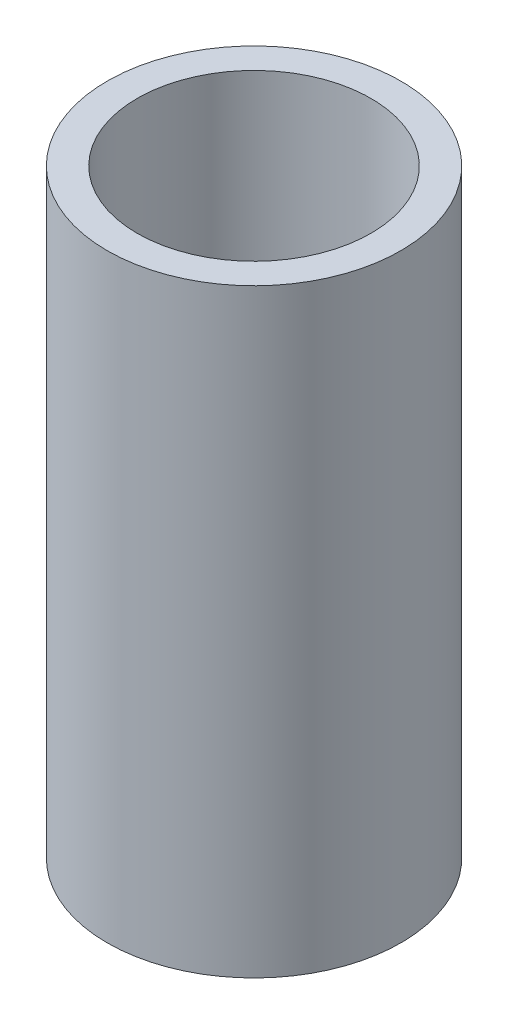
from build123d import *

# Parameters (mm, degrees)
SKETCH1_R           = 24.5
BOSS_EXTRUDE1_DEPTH = 10
SKETCH2_R           = 24.5
SKETCH2_R_2         = 19.5
BOSS_EXTRUDE2_DEPTH = 90


with BuildPart() as part:
    # Sketch1 → Boss-Extrude1 (new body)
    with BuildSketch(Plane(origin=(0, 0, 0), x_dir=(1, 0, 0), z_dir=(0, 1, 0))):
        Circle(SKETCH1_R)
    extrude(amount=BOSS_EXTRUDE1_DEPTH)

    # Sketch2 → Boss-Extrude2 (add)
    with BuildSketch(Plane(origin=(0, 10, 0), x_dir=(1, 0, 0), z_dir=(0, 1, 0))):
        Circle(SKETCH2_R)
        Circle(SKETCH2_R_2, mode=Mode.SUBTRACT)
    extrude(amount=BOSS_EXTRUDE2_DEPTH)


solid = part.part
